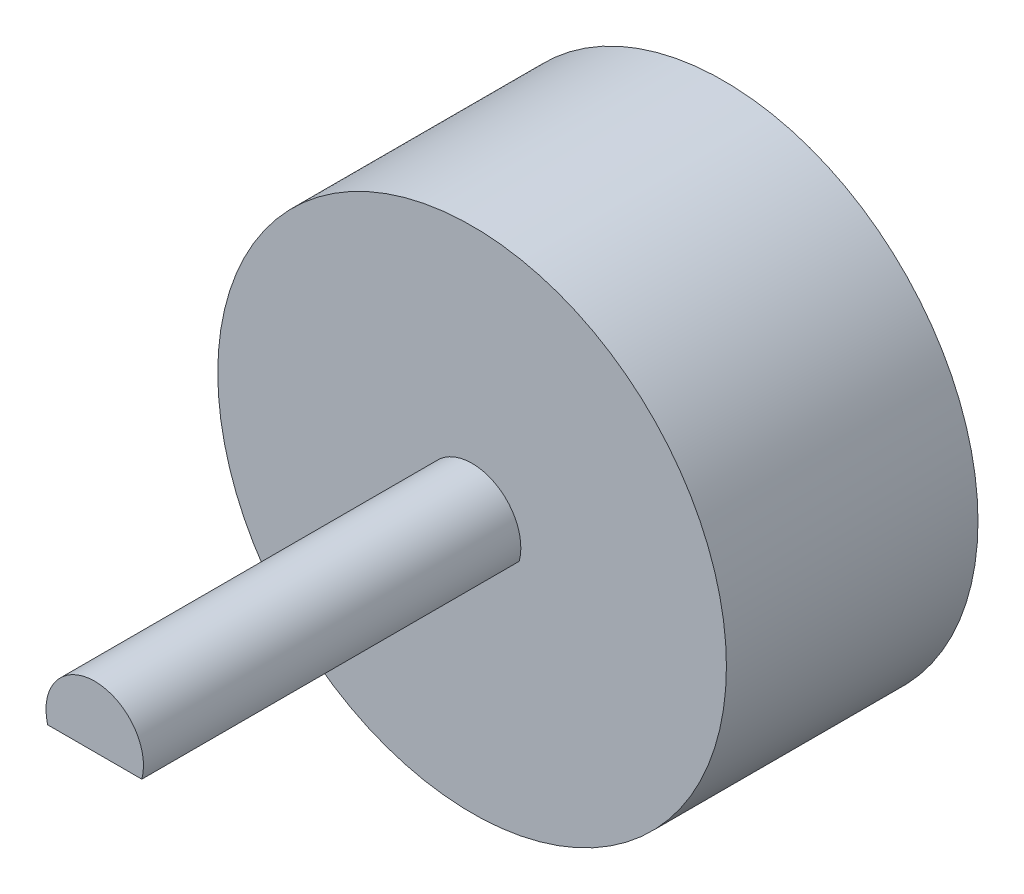
from build123d import *

# Parameters (mm, degrees)
SKETCH1_R           = 16.175
BOSS_EXTRUDE1_DEPTH = 16
BOSS_EXTRUDE2_START = 16
BOSS_EXTRUDE2_DEPTH = 24


with BuildPart() as part:
    # Sketch1 → Boss-Extrude1 (new body)
    with BuildSketch(Plane.XY):
        Circle(SKETCH1_R)
        with BuildLine():
            Line((-2.995, -0.799984375), (2.995, -0.799984375))
            ThreePointArc((2.995, -0.799984375), (0, 3.1), (-2.995, -0.799984375))
        make_face(mode=Mode.SUBTRACT)
        with BuildLine():
            ThreePointArc((-2.995, -0.799984375), (0, 3.1), (2.995, -0.799984375))
            Line((2.995, -0.799984375), (-2.995, -0.799984375))
        make_face()
    extrude(amount=BOSS_EXTRUDE1_DEPTH)

    # Sketch1_3 → Boss-Extrude2 (add)
    with BuildSketch(Plane.XY.offset(BOSS_EXTRUDE2_START)):
        with BuildLine():
            ThreePointArc((-2.995, -0.799984375), (0, 3.1), (2.995, -0.799984375))
            Line((2.995, -0.799984375), (-2.995, -0.799984375))
        make_face()
    extrude(amount=BOSS_EXTRUDE2_DEPTH)


solid = part.part
